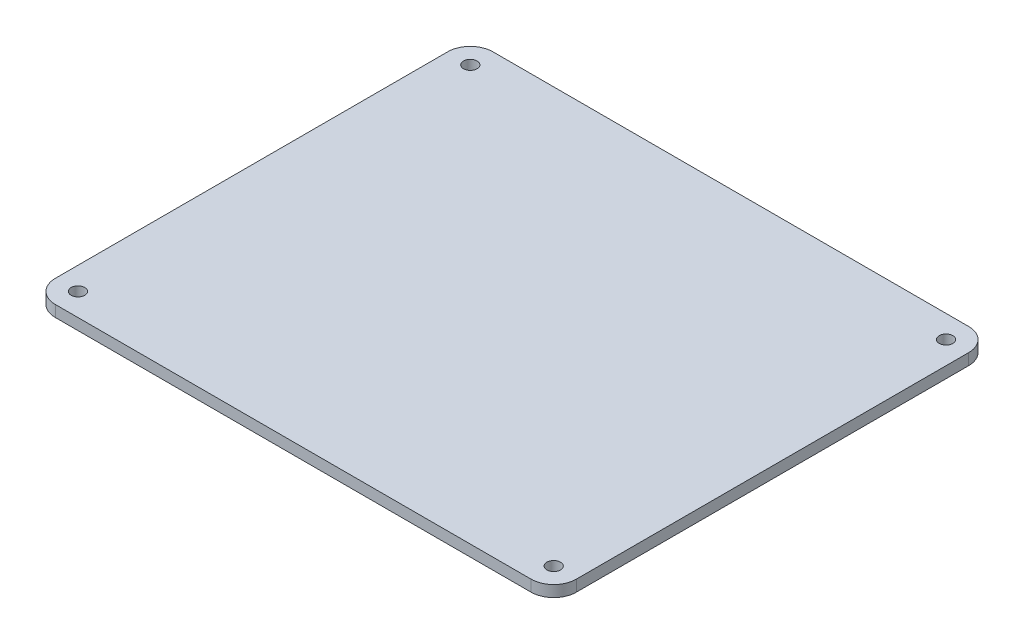
from build123d import *

# Parameters (mm, degrees)
SKETCH_1_R      = 1.5
EXTRUDE_1_DEPTH = 2.5


with BuildPart() as part:
    # 草图1 → 凸台-拉伸1 (new body)
    with BuildSketch(Plane(origin=(0, 24.63711373, 0), x_dir=(1, 0, 0), z_dir=(0, 1, 0))):
        with BuildLine():
            Line((-135.630442735, 34.917702002), (-30.568515715, 34.917702002))
            ThreePointArc((-30.568515715, 34.917702002), (-27.03298181, 33.453235908), (-25.568515715, 29.917702002))
            Line((-25.568515715, 29.917702002), (-25.568515715, -56.727321584))
            ThreePointArc((-25.568515715, -56.727321584), (-27.03298181, -60.26285549), (-30.568515715, -61.727321584))
            Line((-30.568515715, -61.727321584), (-135.630442735, -61.727321584))
            ThreePointArc((-135.630442735, -61.727321584), (-139.16597664, -60.26285549), (-140.630442735, -56.727321584))
            Line((-140.630442735, -56.727321584), (-140.630442735, 29.917702002))
            ThreePointArc((-140.630442735, 29.917702002), (-139.16597664, 33.453235908), (-135.630442735, 34.917702002))
        make_face()
        with Locations((-135.630442735, 29.917702002)):
            Circle(SKETCH_1_R, mode=Mode.SUBTRACT)
        with Locations((-30.568515715, 29.917702002)):
            Circle(SKETCH_1_R, mode=Mode.SUBTRACT)
        with Locations((-30.568515715, -56.727321584)):
            Circle(SKETCH_1_R, mode=Mode.SUBTRACT)
        with Locations((-135.630442735, -56.727321584)):
            Circle(SKETCH_1_R, mode=Mode.SUBTRACT)
    extrude(amount=EXTRUDE_1_DEPTH)


solid = part.part
